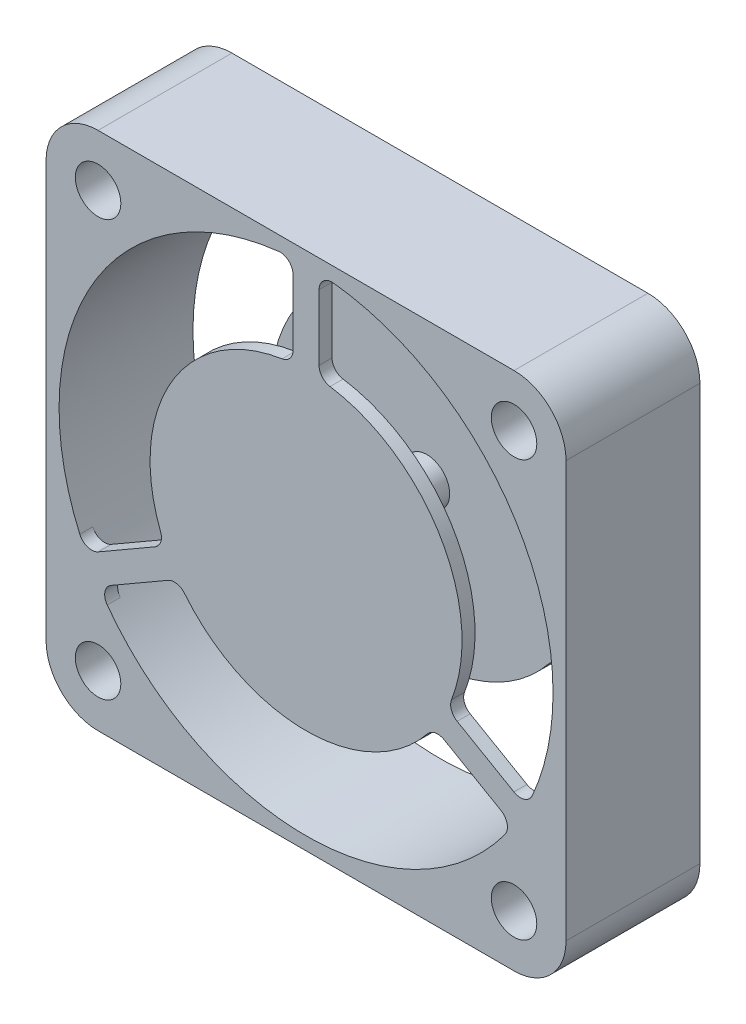
from build123d import *

# Parameters (mm, degrees)
BOSS_EXTRUDE1_DEPTH = 10.3
SKETCH2_R           = 1.75
CUT_EXTRUDE1_DEPTH  = 11.3
SKETCH3_R           = 19
SKETCH3_R_2         = 12
CUT_EXTRUDE2_DEPTH  = 11.3
BOSS_EXTRUDE2_DEPTH = 10.3
CIRPATTERN1_COUNT   = 3
FILLET2_R           = 1
CUT_EXTRUDE3_START  = 1
SKETCH5_R           = 19
CUT_EXTRUDE3_DEPTH  = 8.3
SKETCH6_R           = 1.75
BOSS_EXTRUDE3_DEPTH = 8.3


with BuildPart() as part:
    # Sketch1 → Boss-Extrude1 (new body)
    with BuildSketch(Plane.XY):
        with BuildLine():
            Line((0, -4), (32, -4))
            ThreePointArc((32, -4), (34.828427125, -2.828427125), (36, 0))
            Line((36, 0), (36, 32))
            ThreePointArc((36, 32), (34.828427125, 34.828427125), (32, 36))
            Line((32, 36), (0, 36))
            ThreePointArc((0, 36), (-2.828427125, 34.828427125), (-4, 32))
            Line((-4, 32), (-4, 0))
            ThreePointArc((-4, 0), (-2.828427125, -2.828427125), (0, -4))
        make_face()
    extrude(amount=BOSS_EXTRUDE1_DEPTH)

    # Sketch2 → Cut-Extrude1 (cut, through all)
    with BuildSketch(Plane.XY.offset(10.3)):
        Circle(SKETCH2_R)
        with Locations((0, 32)):
            Circle(SKETCH2_R)
        with Locations((32, 0)):
            Circle(SKETCH2_R)
        with Locations((32, 32)):
            Circle(SKETCH2_R)
    extrude(amount=-CUT_EXTRUDE1_DEPTH, mode=Mode.SUBTRACT)

    # Sketch3 → Cut-Extrude2 (cut, through all)
    with BuildSketch(Plane.XY.offset(10.3)):
        with Locations((16, 16)):
            Circle(SKETCH3_R)
        with Locations((16, 16)):
            Circle(SKETCH3_R_2, mode=Mode.SUBTRACT)
    extrude(amount=-CUT_EXTRUDE2_DEPTH, mode=Mode.SUBTRACT)

    # Sketch4 → Boss-Extrude2 (add)
    with BuildSketch(Plane.XY):
        with BuildLine():
            Line((15, 27.958260743), (15, 34.973665961))
            ThreePointArc((15, 34.973665961), (16, 35), (17, 34.973665961))
            Line((17, 34.973665961), (17, 27.958260743))
            ThreePointArc((17, 27.958260743), (16, 28), (15, 27.958260743))
        make_face()
    boss_extrude2 = extrude(amount=BOSS_EXTRUDE2_DEPTH)

    # CirPattern1: Boss-Extrude2 ×3 about axis
    cirpattern1_axis = Axis((16, 16, 0), (0, 0, 1))
    for i in range(1, CIRPATTERN1_COUNT):
        add(boss_extrude2.rotate(cirpattern1_axis, i * 360 / CIRPATTERN1_COUNT))

    # Fillet2
    fillet2_edges = [part.edges().sort_by_distance(p)[0] for p in [
        (15, 27.958260743, 5.15),
        (17, 27.958260743, 5.15),
        (17, 34.973665961, 5.15),
        (15, 34.973665961, 5.15),
        (6.143842411, 9.154844225, 5.15),
        (5.143842411, 10.886895032, 5.15),
        (-0.931676725, 7.379192423, 5.15),
        (0.068323275, 5.647141616, 5.15),
        (26.856157589, 10.886895032, 5.15),
        (25.856157589, 9.154844225, 5.15),
        (31.931676725, 5.647141616, 5.15),
        (32.931676725, 7.379192423, 5.15),
    ]]
    fillet(fillet2_edges, radius=FILLET2_R)

    # Sketch5 → Cut-Extrude3 (cut)
    with BuildSketch(Plane.XY.offset(CUT_EXTRUDE3_START)):
        with Locations((16, 16)):
            Circle(SKETCH5_R)
    extrude(amount=CUT_EXTRUDE3_DEPTH, mode=Mode.SUBTRACT)

    # Sketch6 → Boss-Extrude3 (add)
    with BuildSketch(Plane.XY.offset(1)):
        with Locations((16, 16)):
            Circle(SKETCH6_R)
    extrude(amount=BOSS_EXTRUDE3_DEPTH)


solid = part.part
